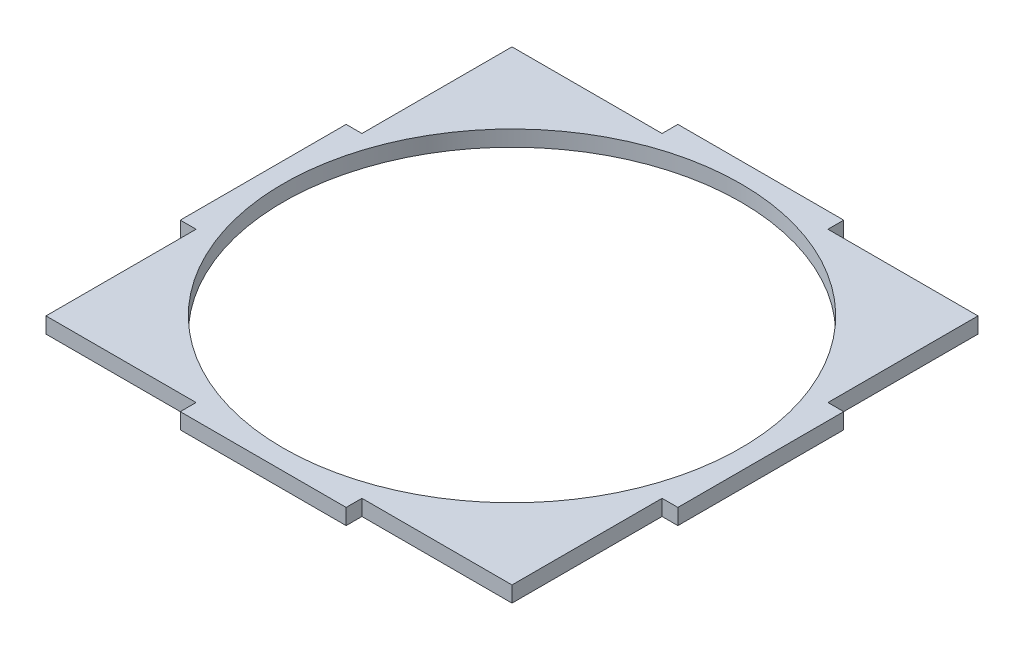
from build123d import *

# Parameters (mm, degrees)
SKETCH2_R           = 46
BOSS_EXTRUDE1_DEPTH = 3.175


with BuildPart() as part:
    # Sketch2 → Boss-Extrude1 (new body)
    with BuildSketch(Plane(origin=(0, 0, 0), x_dir=(1, 0, 0), z_dir=(0, 1, 0))):
        Polygon((-50, -16.666666667), (-50, 16.666666667), (-46.825, 16.666666667), (-46.825, 46.825), (-16.666666667, 46.825), (-16.666666667, 50), (16.666666667, 50), (16.666666667, 46.825), (46.825, 46.825), (46.825, 16.666666667), (50, 16.666666667), (50, -16.666666667), (46.825, -16.666666667), (46.825, -46.825), (16.666666667, -46.825), (16.666666667, -50), (-16.666666667, -50), (-16.666666667, -46.825), (-46.825, -46.825), (-46.825, -16.666666667), align=None)
        Circle(SKETCH2_R, mode=Mode.SUBTRACT)
    extrude(amount=BOSS_EXTRUDE1_DEPTH)


solid = part.part
